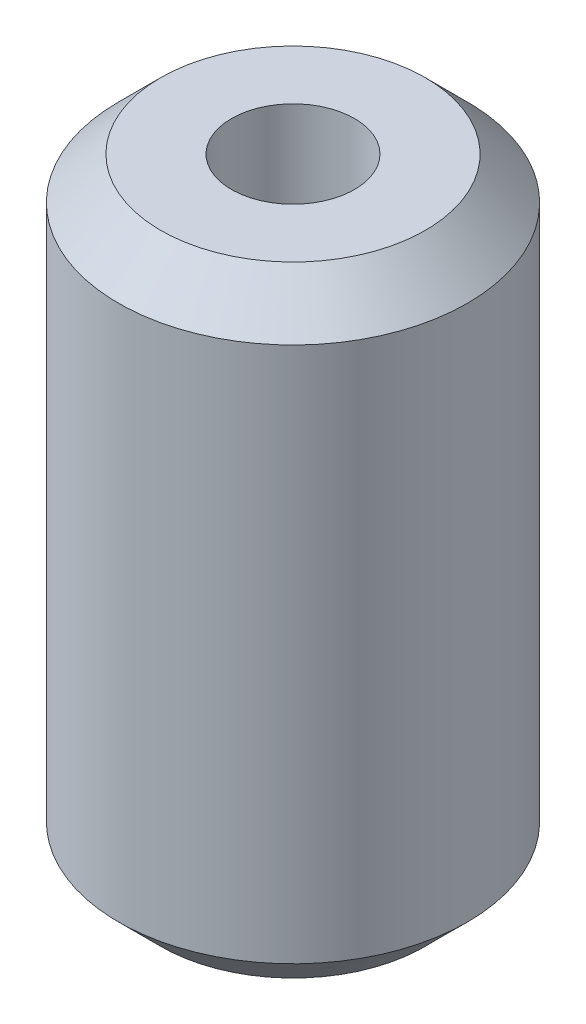
from build123d import *


with BuildPart() as part:
    # Esquisse1 → Révolution1 (revolve)
    with BuildSketch(Plane.XY):
        Polygon((-3.175, -15.457041255), (-6.827672759, -15.457041255), (-9, -13.284714014), (-9, 14.370631503), (-6.827672759, 16.542958745), (-3.175, 16.542958745), align=None)
    revolve(axis=Axis((0, 16.542958745, 0), (0, -1, 0)))


solid = part.part
